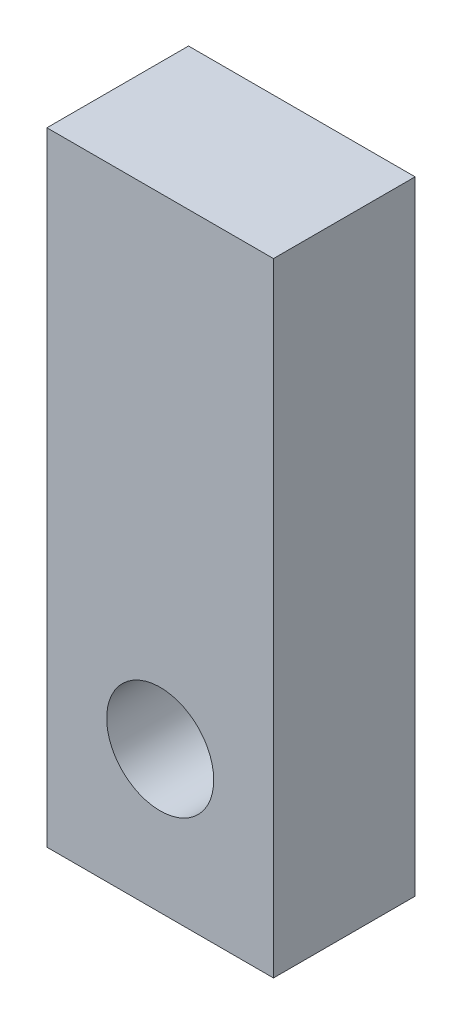
from build123d import *

# Parameters (mm, degrees)
SKIZZE1_W                       = 8
SKIZZE1_H                       = 22
AUFSATZ_LINEAR_AUSTRAGEN1_DEPTH = 5
M4_GEWINDEBOHRUNG1_D            = 3.78


with BuildPart() as part:
    # Skizze1 → Aufsatz-Linear austragen1 (new body)
    with BuildSketch(Plane.XY):
        with Locations((0, 6)):
            Rectangle(SKIZZE1_W, SKIZZE1_H)
    extrude(amount=AUFSATZ_LINEAR_AUSTRAGEN1_DEPTH)

    # M4 Gewindebohrung1 (through all)
    with Locations(Plane.XY.offset(5)):
        with Locations((0, 0)):
            Hole(M4_GEWINDEBOHRUNG1_D / 2)


solid = part.part
